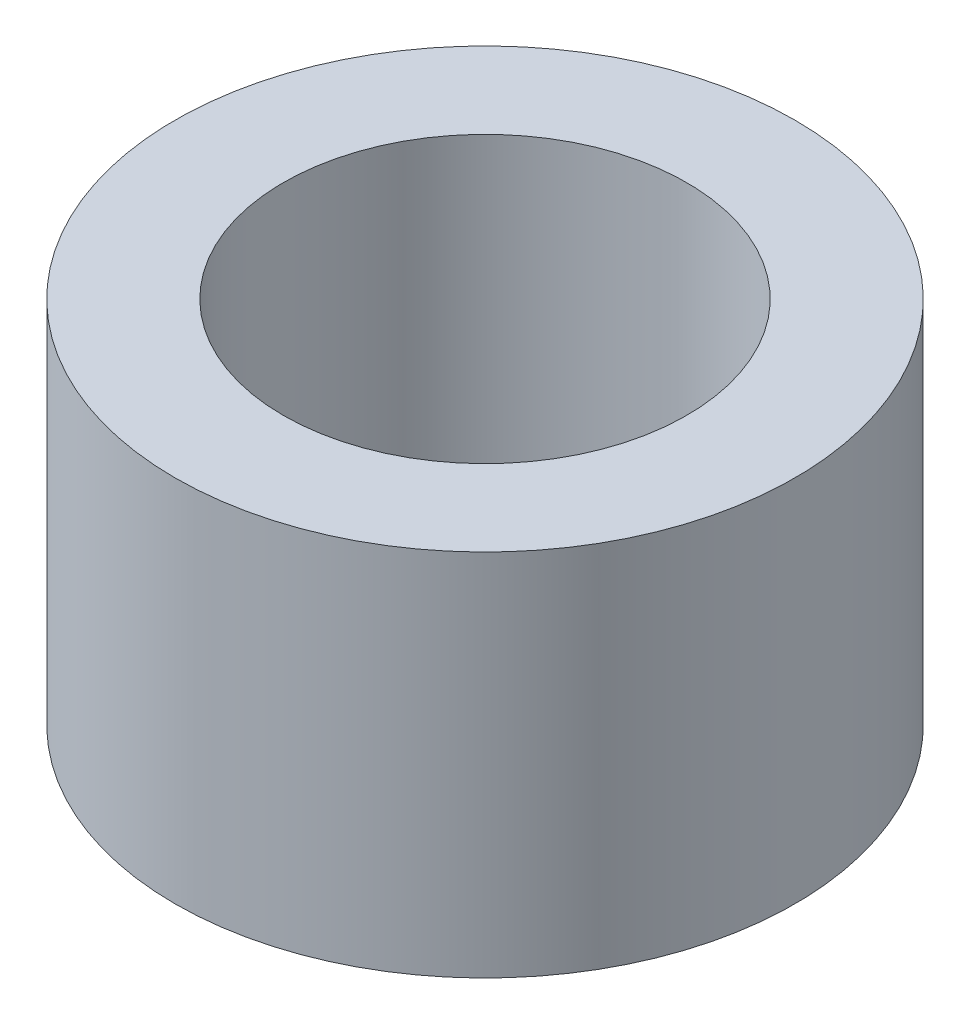
from build123d import *

# Parameters (mm, degrees)
CROQUIS1_R              = 6.3
CROQUIS1_R_2            = 4.1
SALIENTE_EXTRUIR1_DEPTH = 7.5


with BuildPart() as part:
    # Croquis1 → Saliente-Extruir1 (new body)
    with BuildSketch(Plane(origin=(0, 0, 0), x_dir=(1, 0, 0), z_dir=(0, 1, 0))):
        Circle(CROQUIS1_R)
        Circle(CROQUIS1_R_2, mode=Mode.SUBTRACT)
    extrude(amount=SALIENTE_EXTRUIR1_DEPTH)


solid = part.part
